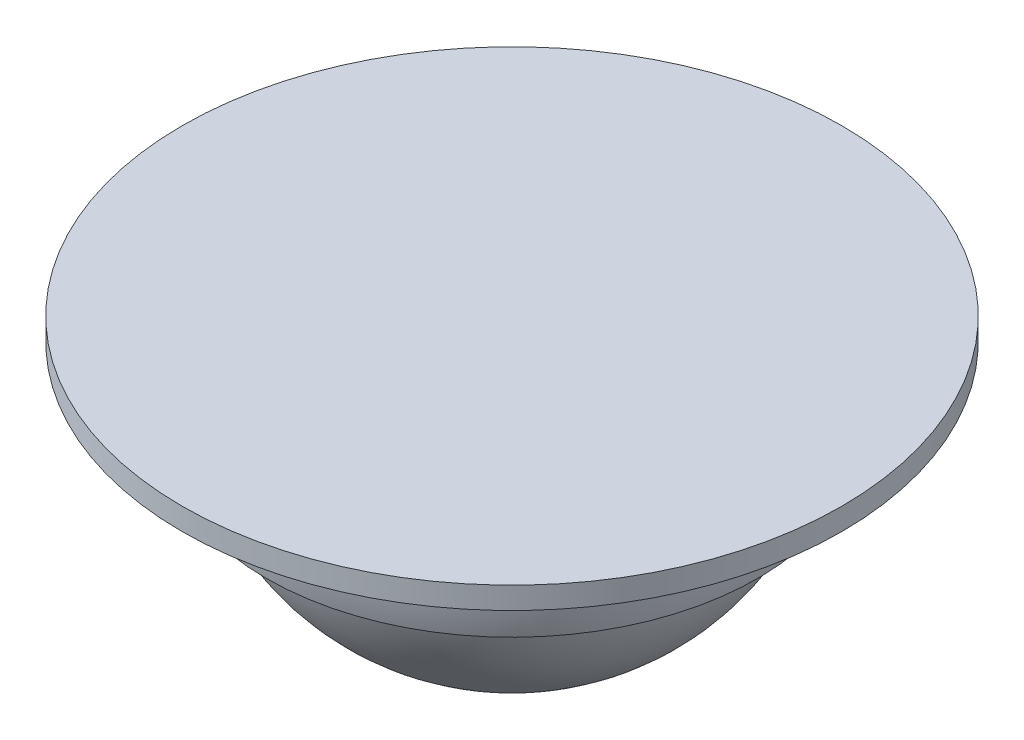
from build123d import *


with BuildPart() as part:
    # Sketch1 → Revolve1 (revolve)
    with BuildSketch(Plane.XY):
        with BuildLine():
            Line((0, 0), (-30, 0))
            Line((-30, 0), (-30, -2))
            Line((-30, -2), (-22.912878475, -2))
            ThreePointArc((-22.912878475, -2), (-22.930059657, -5.792306925), (-22.323842868, -9.535886523))
            Line((-22.323842868, -9.535886523), (-20.257195275, -9.535886523))
            ThreePointArc((-20.257195275, -9.535886523), (-12.742573975, -20.692118155), (0, -25))
            Line((0, -25), (0, 0))
        make_face()
    revolve(axis=Axis((0, 0, 0), (0, -1, 0)))


solid = part.part
